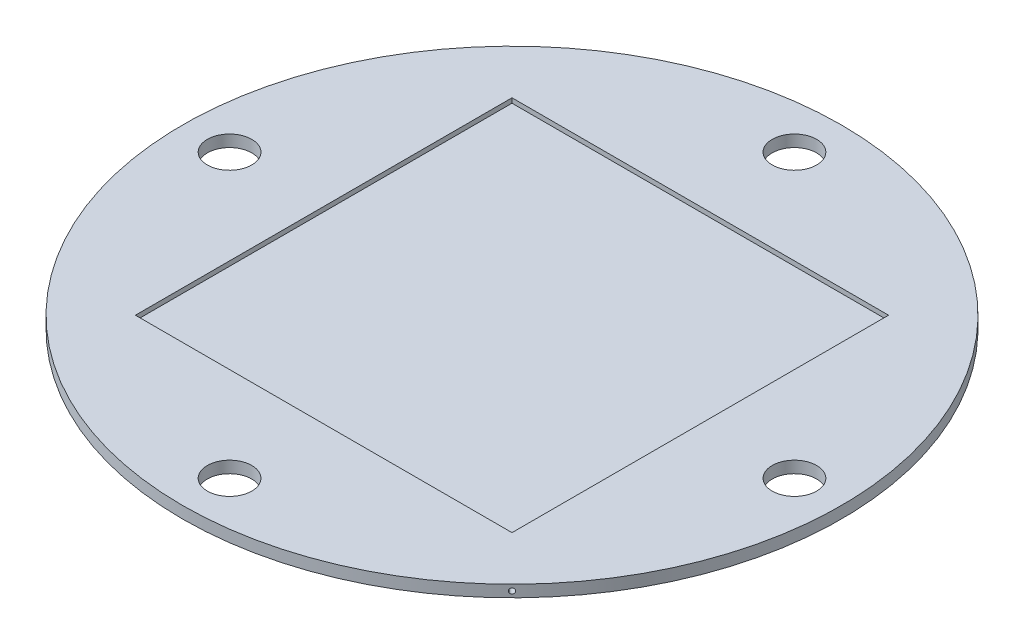
from build123d import *

# Parameters (mm, degrees)
SKETCH1_R           = 88.9
BOSS_EXTRUDE1_DEPTH = 3.175
SKETCH2_R           = 5.9944
CUT_EXTRUDE1_DEPTH  = 4.175
CIRPATTERN1_COUNT   = 4
SKETCH3_R           = 0.6985
CUT_EXTRUDE2_DEPTH  = 3.175
CIRPATTERN2_COUNT   = 4
SKETCH4_W           = 101.6
SKETCH4_H           = 101.6
CUT_EXTRUDE3_DEPTH  = 1.27


with BuildPart() as part:
    # Sketch1 → Boss-Extrude1 (new body)
    with BuildSketch(Plane(origin=(0, 0, 0), x_dir=(1, 0, 0), z_dir=(0, 1, 0))):
        Circle(SKETCH1_R)
    extrude(amount=BOSS_EXTRUDE1_DEPTH)

    # Sketch2 → Cut-Extrude1 (cut, through all)
    with BuildSketch(Plane(origin=(0, 3.175, 0), x_dir=(1, 0, 0), z_dir=(0, 1, 0))):
        with Locations((0, 76.2)):
            Circle(SKETCH2_R)
    cut_extrude1 = extrude(amount=-CUT_EXTRUDE1_DEPTH, mode=Mode.SUBTRACT)

    # CirPattern1: Cut-Extrude1 ×4 about axis
    cirpattern1_axis = Axis((0, 0, 0), (0, 1, 0))
    for i in range(1, CIRPATTERN1_COUNT):
        add(cut_extrude1.rotate(cirpattern1_axis, i * 360 / CIRPATTERN1_COUNT), mode=Mode.SUBTRACT)

    # Sketch3 → Cut-Extrude2 (cut)
    with BuildSketch(Plane(origin=(-62.861792847, 0, 62.861792847), x_dir=(0, -1, 0), z_dir=(-0.707106781, 0, 0.707106781))):
        with Locations((-1.5875, 0)):
            Circle(SKETCH3_R)
    cut_extrude2 = extrude(amount=-CUT_EXTRUDE2_DEPTH, mode=Mode.SUBTRACT)

    # CirPattern2: Cut-Extrude2 ×4 about axis
    cirpattern2_axis = Axis((0, 0, 0), (0, 1, 0))
    for i in range(1, CIRPATTERN2_COUNT):
        add(cut_extrude2.rotate(cirpattern2_axis, i * 360 / CIRPATTERN2_COUNT), mode=Mode.SUBTRACT)

    # Sketch4 → Cut-Extrude3 (cut)
    with BuildSketch(Plane(origin=(0, 3.175, 0), x_dir=(1, 0, 0), z_dir=(0, 1, 0))):
        Rectangle(SKETCH4_W, SKETCH4_H)
    extrude(amount=-CUT_EXTRUDE3_DEPTH, mode=Mode.SUBTRACT)


solid = part.part
